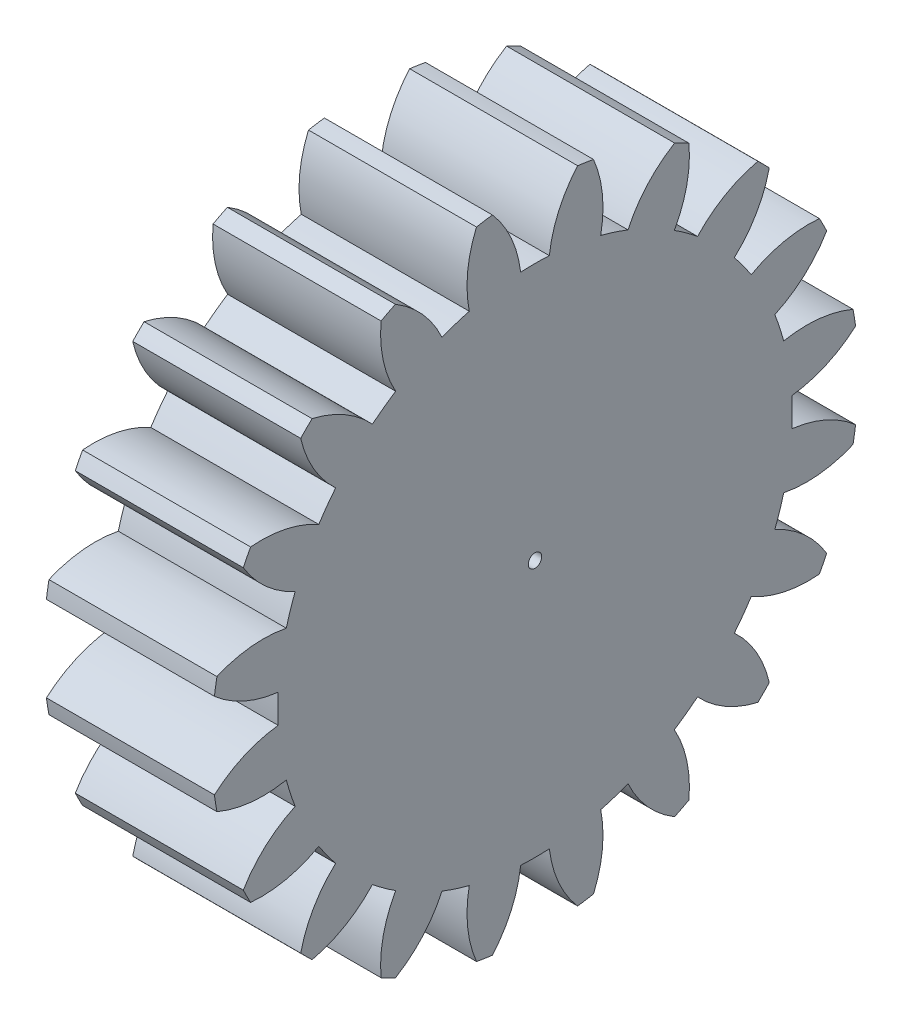
from build123d import *

# Parameters (mm, degrees)
BASPROSKE_W     = 10
BASPROSKE_H     = 19.25
TOOTHCUT_DEPTH  = 30.002155092
TEETHCUTS_COUNT = 20
TEETHCUTS_ANGLE = 342
BORSKE_R        = 0.4
BORE_DEPTH      = 50.0000508


with BuildPart() as part:
    # BasProSke → Base-Revolve (revolve)
    with BuildSketch(Plane(origin=(0, 0, 0), x_dir=(1, 0, 0), z_dir=(0, 1, 0)), mode=Mode.PRIVATE) as base_revolve_sk:
        with Locations((5, 9.625)):
            Rectangle(BASPROSKE_W, BASPROSKE_H)
    revolve(base_revolve_sk.sketch.rotate(Axis((-10, 0, 0), (1, 0, 0)), 180), axis=Axis((-10, 0, 0), (1, 0, 0)))

    # TooCutSke → ToothCut (cut, through all)
    with BuildSketch(Plane(origin=(0, 0, 0), x_dir=(0, 0, -1), z_dir=(1, 0, 0))):
        with BuildLine():
            ThreePointArc((0.85426341, 15.287650777), (0, 15.3115), (-0.85426341, 15.287650777))
            ThreePointArc((-0.85426341, 15.287650777), (-1.414533498, 17.326428412), (-2.557997552, 19.104912815))
            ThreePointArc((-2.557997552, 19.104912815), (0, 19.2754), (2.557997552, 19.104912815))
            ThreePointArc((2.557997552, 19.104912815), (1.414533498, 17.326428412), (0.85426341, 15.287650777))
        make_face()
    toothcut = extrude(amount=TOOTHCUT_DEPTH, mode=Mode.SUBTRACT)

    # TeethCuts: ToothCut ×20 about axis
    teethcuts_axis = Axis((-10, 0, 0), (1, 0, 0))
    for i in range(1, TEETHCUTS_COUNT):
        add(toothcut.rotate(teethcuts_axis, i * TEETHCUTS_ANGLE / (TEETHCUTS_COUNT - 1)), mode=Mode.SUBTRACT)

    # BorSke → Bore (cut, symmetric)
    with BuildSketch(Plane(origin=(0, 0, 0), x_dir=(0, 0, -1), z_dir=(1, 0, 0))):
        with Locations(Location((0, 0, 0), (0, 0, 180))):
            Circle(BORSKE_R)
    extrude(amount=BORE_DEPTH, both=True, mode=Mode.SUBTRACT)


solid = part.part
